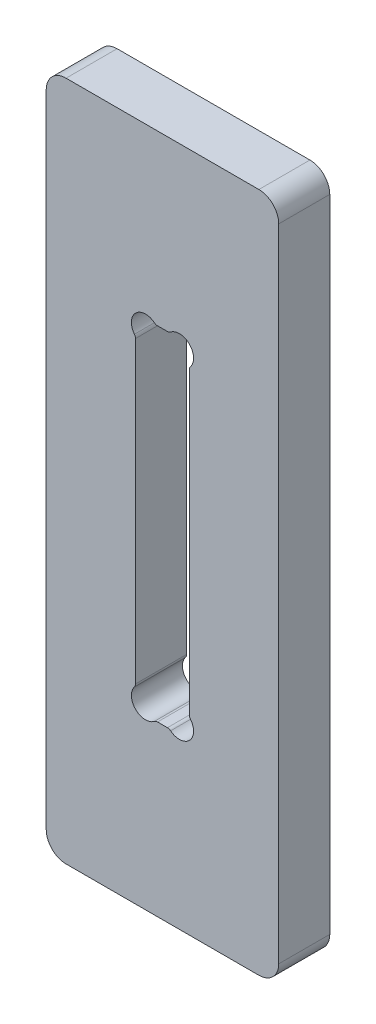
from build123d import *

# Parameters (mm, degrees)
SKETCH1_W           = 82
SKETCH1_H           = 240
BOSS_EXTRUDE1_DEPTH = 18
CUT_EXTRUDE1_DEPTH  = 19
FILLET1_R           = 7


with BuildPart() as part:
    # Sketch1 → Boss-Extrude1 (new body)
    with BuildSketch(Plane.XY):
        with Locations((41, 120)):
            Rectangle(SKETCH1_W, SKETCH1_H)
    extrude(amount=BOSS_EXTRUDE1_DEPTH)

    # Sketch2 → Cut-Extrude1 (cut, through all)
    with BuildSketch(Plane.XY):
        with BuildLine():
            Line((39.251228148, 59.5), (42.748771852, 59.5))
            ThreePointArc((42.748771852, 59.5), (43.339438857, 59.400327171), (43.864690916, 59.11234721))
            ThreePointArc((43.864690916, 59.11234721), (50.5, 59.5), (50.88765279, 66.135309084))
            ThreePointArc((50.88765279, 66.135309084), (50.599672829, 66.660561143), (50.5, 67.251228148))
            Line((50.5, 67.251228148), (50.5, 172.748771852))
            ThreePointArc((50.5, 172.748771852), (50.599672829, 173.339438857), (50.88765279, 173.864690916))
            ThreePointArc((50.88765279, 173.864690916), (50.5, 180.5), (43.864690916, 180.88765279))
            ThreePointArc((43.864690916, 180.88765279), (43.339438857, 180.599672829), (42.748771852, 180.5))
            Line((42.748771852, 180.5), (39.251228148, 180.5))
            ThreePointArc((39.251228148, 180.5), (38.660561143, 180.599672829), (38.135309084, 180.88765279))
            ThreePointArc((38.135309084, 180.88765279), (31.5, 180.5), (31.11234721, 173.864690916))
            ThreePointArc((31.11234721, 173.864690916), (31.400327171, 173.339438857), (31.5, 172.748771852))
            Line((31.5, 172.748771852), (31.5, 67.251228148))
            ThreePointArc((31.5, 67.251228148), (31.400327171, 66.660561143), (31.11234721, 66.135309084))
            ThreePointArc((31.11234721, 66.135309084), (31.5, 59.5), (38.135309084, 59.11234721))
            ThreePointArc((38.135309084, 59.11234721), (38.660561143, 59.400327171), (39.251228148, 59.5))
        make_face()
    extrude(amount=CUT_EXTRUDE1_DEPTH, mode=Mode.SUBTRACT)

    # Fillet1
    fillet1_edges = [part.edges().sort_by_distance(p)[0] for p in [
        (0, 240, 9),
        (82, 240, 9),
        (82, 0, 9),
        (0, 0, 9),
    ]]
    fillet(fillet1_edges, radius=FILLET1_R)


solid = part.part
